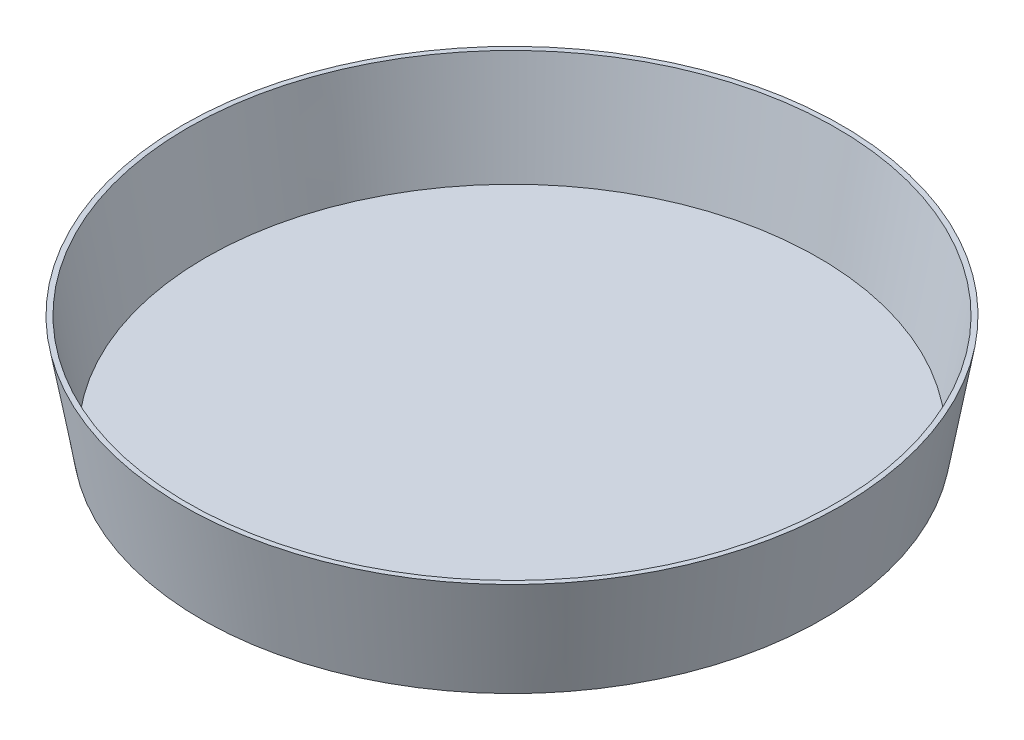
from build123d import *

# Parameters (mm, degrees)
SHELL2_T = 3


with BuildPart() as part:
    # Sketch1 → Revolve1 (revolve)
    with BuildSketch(Plane.XY, mode=Mode.PRIVATE) as revolve1_sk:
        Polygon((0, 0), (0, -63.5), (188.803236725, -63.5), (200, 0), align=None)
    revolve(revolve1_sk.sketch.rotate(Axis((0, 0, 0), (0, -1, 0)), 180), axis=Axis((0, 0, 0), (0, -1, 0)))

    # Shell2
    shell2_openings = [part.faces().sort_by_distance(p)[0] for p in [
        (0, 0, 0),
    ]]
    offset(amount=SHELL2_T, openings=shell2_openings, kind=Kind.INTERSECTION)


solid = part.part
